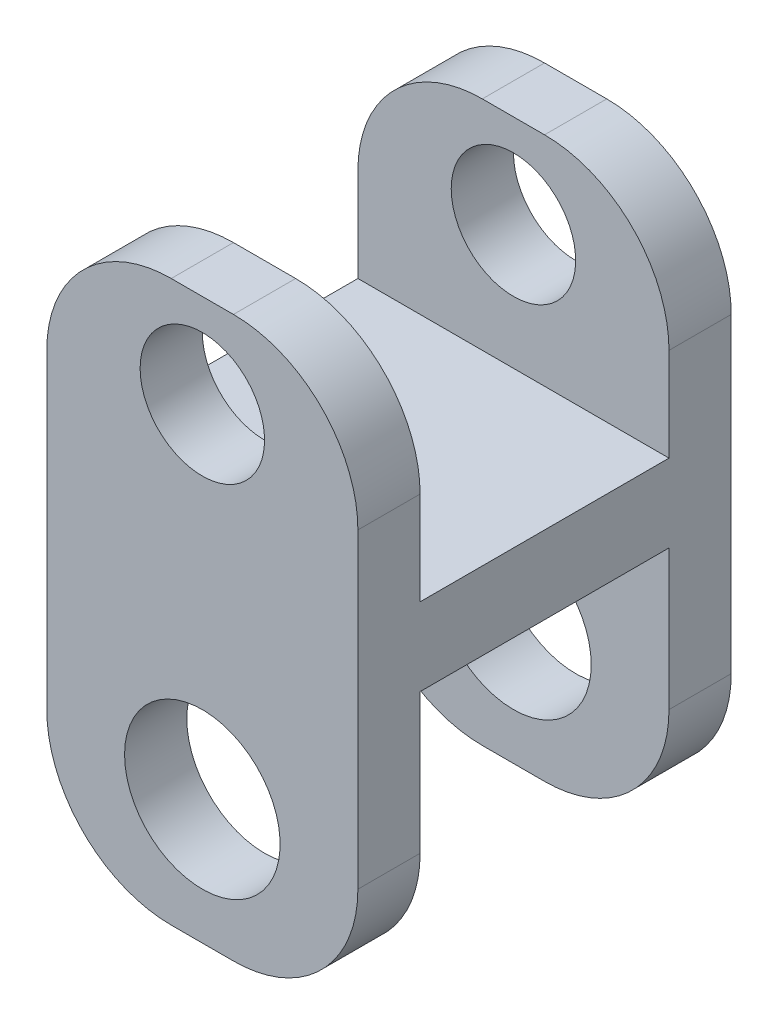
from build123d import *

# Parameters (mm, degrees)
SALIENTE_EXTRUIR1_DEPTH = 5
CROQUIS2_R              = 2
CROQUIS2_R_2            = 2.5
CORTAR_EXTRUIR1_DEPTH   = 12
REDONDEO1_R             = 4


with BuildPart() as part:
    # Croquis1 → Saliente-Extruir1 (new body, symmetric)
    with BuildSketch(Plane(origin=(0, 0, 0), x_dir=(0, 0, -1), z_dir=(1, 0, 0))):
        Polygon((4, 9), (6, 9), (6, -9), (4, -9), (4, -0.5), (-4, -0.5), (-4, -9), (-6, -9), (-6, 9), (-4, 9), (-4, 2), (4, 2), align=None)
    extrude(amount=SALIENTE_EXTRUIR1_DEPTH, both=True)

    # Croquis2 → Cortar-Extruir1 (cut)
    with BuildSketch(Plane(origin=(0, 0, -6), x_dir=(-1, 0, 0), z_dir=(0, 0, -1))):
        with Locations((0, 6)):
            Circle(CROQUIS2_R)
        with Locations((0, -5)):
            Circle(CROQUIS2_R_2)
    extrude(amount=-CORTAR_EXTRUIR1_DEPTH, mode=Mode.SUBTRACT)

    # Redondeo1
    redondeo1_edges = [part.edges().sort_by_distance(p)[0] for p in [
        (-5, -9, -5),
        (-5, -9, 5),
        (-5, 9, 5),
        (-5, 9, -5),
        (5, 9, 5),
        (5, -9, 5),
        (5, -9, -5),
        (5, 9, -5),
    ]]
    fillet(redondeo1_edges, radius=REDONDEO1_R)


solid = part.part
